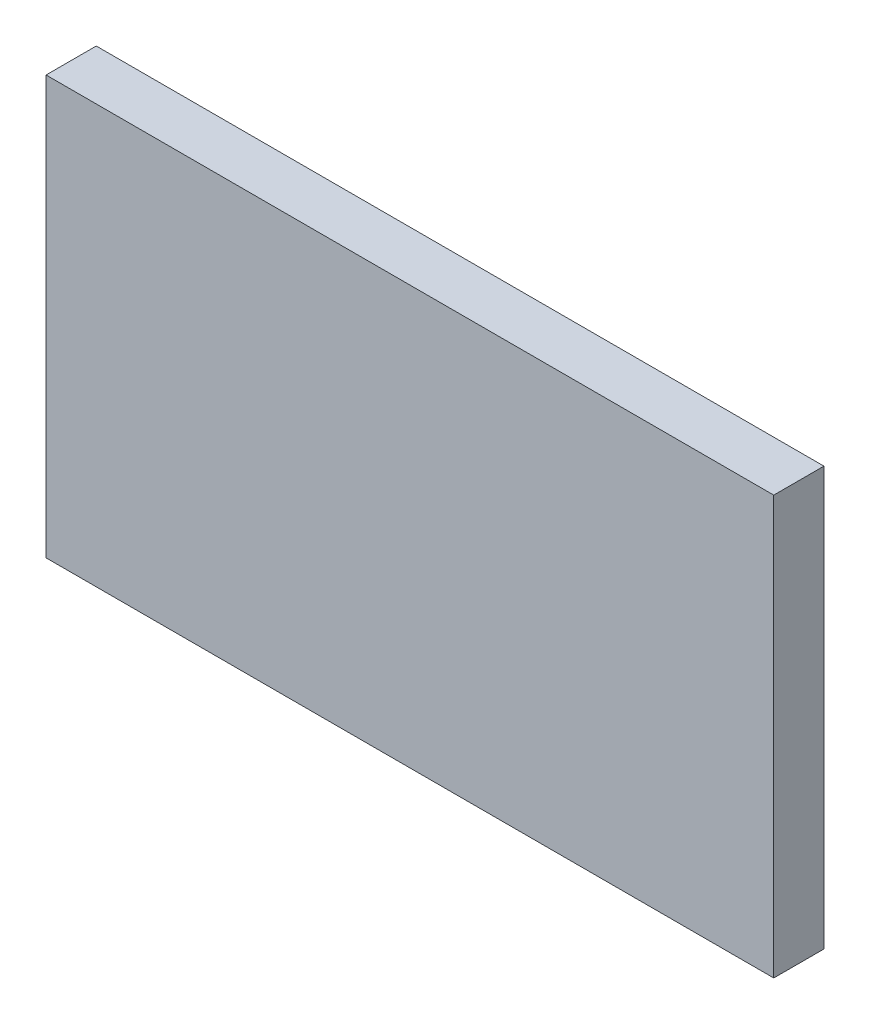
from build123d import *

# Parameters (mm, degrees)
CROQUIS1_W              = 174
CROQUIS1_H              = 100
SALIENTE_EXTRUIR1_DEPTH = 12


with BuildPart() as part:
    # Croquis1 → Saliente-Extruir1 (new body)
    with BuildSketch(Plane.XY):
        with Locations((87, 50)):
            Rectangle(CROQUIS1_W, CROQUIS1_H)
    extrude(amount=SALIENTE_EXTRUIR1_DEPTH)


solid = part.part
